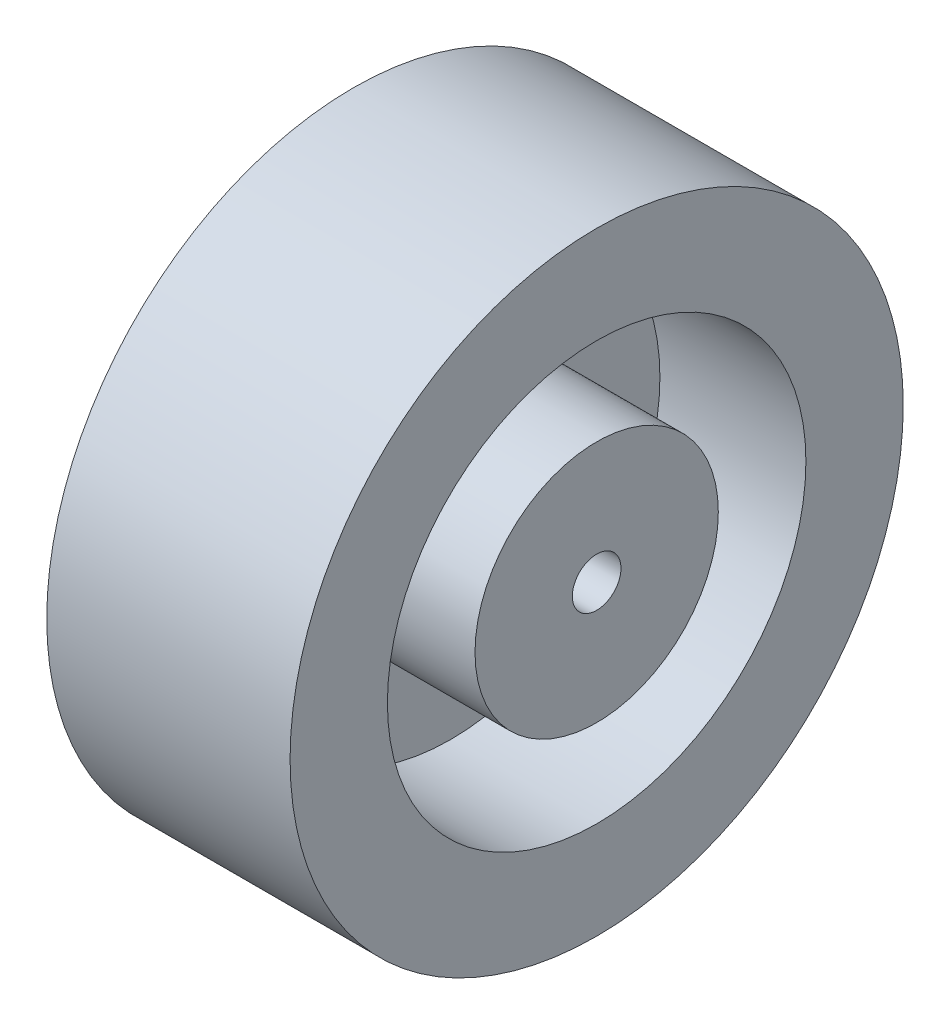
from build123d import *

# Parameters (mm, degrees)
SKETCH1_R           = 31.5
BOSS_EXTRUDE1_DEPTH = 25
SKETCH3_R           = 2.5
CUT_EXTRUDE1_DEPTH  = 25
SHELL1_T            = -10


with BuildPart() as part:
    # Sketch1 → Boss-Extrude1 (new body)
    with BuildSketch(Plane(origin=(0, 0, 0), x_dir=(0, 0, -1), z_dir=(1, 0, 0))):
        Circle(SKETCH1_R)
    extrude(amount=BOSS_EXTRUDE1_DEPTH)

    # Sketch3 → Cut-Extrude1 (cut)
    with BuildSketch(Plane.ZY):
        Circle(SKETCH3_R)
    extrude(amount=-CUT_EXTRUDE1_DEPTH, mode=Mode.SUBTRACT)

    # Shell1
    shell1_openings = [part.faces().sort_by_distance(p)[0] for p in [
        (25, 0, 2.5),
    ]]
    offset(amount=SHELL1_T, openings=shell1_openings, kind=Kind.INTERSECTION)


solid = part.part
